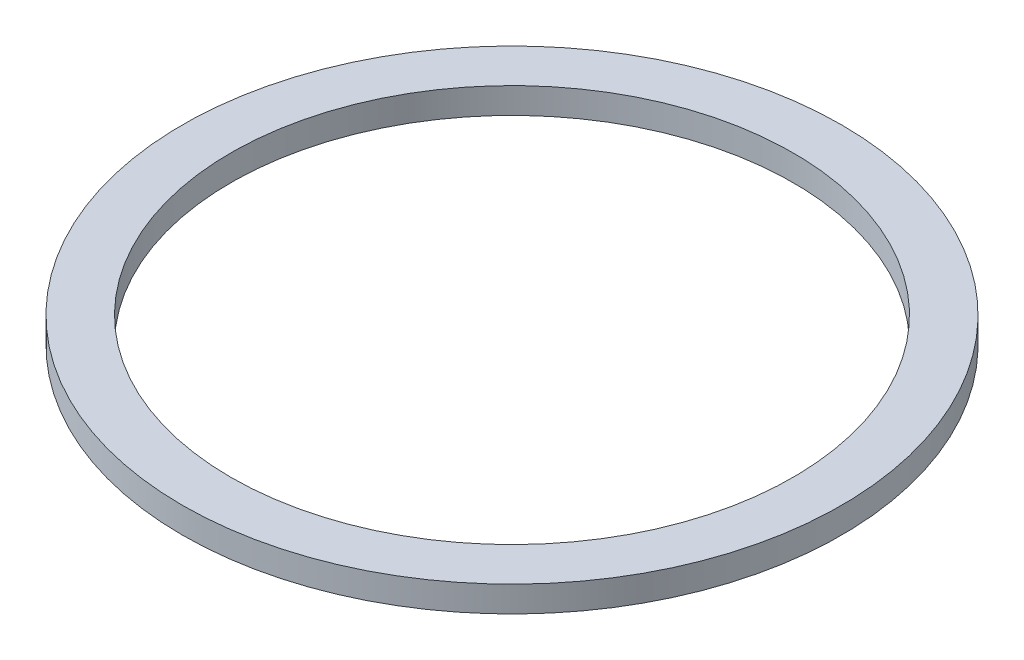
from build123d import *

# Parameters (mm, degrees)
SKETCH1_R           = 10.2
SKETCH1_R_2         = 8.7
BOSS_EXTRUDE1_DEPTH = 0.8


with BuildPart() as part:
    # Sketch1 → Boss-Extrude1 (new body)
    with BuildSketch(Plane(origin=(0, 0, 0), x_dir=(1, 0, 0), z_dir=(0, 1, 0))):
        Circle(SKETCH1_R)
        Circle(SKETCH1_R_2, mode=Mode.SUBTRACT)
    extrude(amount=BOSS_EXTRUDE1_DEPTH)


solid = part.part
